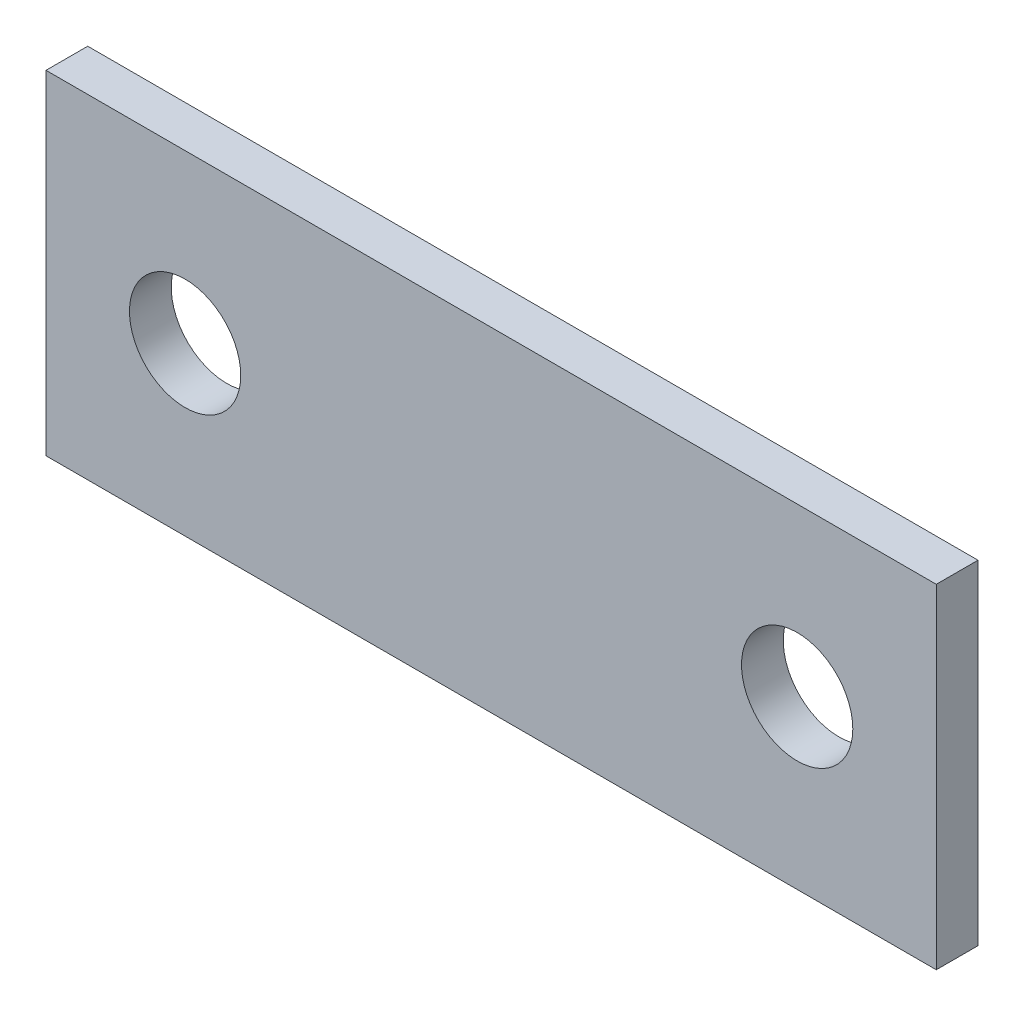
from build123d import *

# Parameters (mm, degrees)
SKETCH1_W           = 50.8
SKETCH1_H           = 19.05
SKETCH1_R           = 3.175
BOSS_EXTRUDE1_DEPTH = 2.38125


with BuildPart() as part:
    # Sketch1 → Boss-Extrude1 (new body)
    with BuildSketch(Plane.XY):
        Rectangle(SKETCH1_W, SKETCH1_H)
        with Locations((-17.4625, 0)):
            Circle(SKETCH1_R, mode=Mode.SUBTRACT)
        with Locations((17.4625, 0)):
            Circle(SKETCH1_R, mode=Mode.SUBTRACT)
    extrude(amount=BOSS_EXTRUDE1_DEPTH)


solid = part.part
